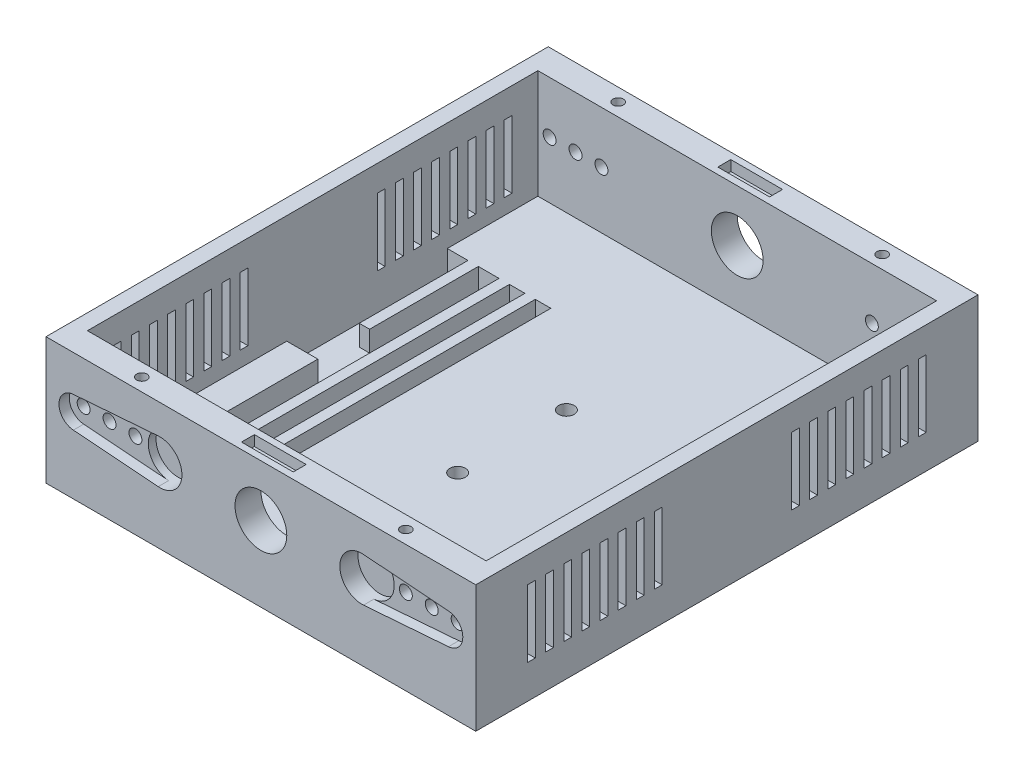
from build123d import *

# Parameters (mm, degrees)
SKETCH1_W           = 83
SKETCH1_H           = 97
BOSS_EXTRUDE1_DEPTH = 6
SKETCH2_W           = 83
SKETCH2_H           = 97
SKETCH2_W_2         = 77
SKETCH2_H_2         = 87
BOSS_EXTRUDE2_DEPTH = 21
SKETCH3_R           = 4.25
CUT_EXTRUDE1_DEPTH  = 3.5
CUT_EXTRUDE2_DEPTH  = 2
SKETCH6_R           = 1.25
CUT_EXTRUDE4_DEPTH  = 5
SKETCH10_R          = 1.5
CUT_EXTRUDE5_DEPTH  = 10
SKETCH11_W          = 3
SKETCH11_H          = 52
CUT_EXTRUDE6_DEPTH  = 4
SKETCH12_W          = 10
SKETCH12_H          = 2.5
CUT_EXTRUDE7_DEPTH  = 2
SKETCH13_R          = 1
CUT_EXTRUDE8_DEPTH  = 5
SKETCH15_W          = 1.5
SKETCH15_H          = 13
CUT_EXTRUDE9_DEPTH  = 101
CHAMFER2_SIZE       = 2.5
SKETCH17_R          = 5
CUT_EXTRUDE10_DEPTH = 105
SKETCH19_W          = 8
SKETCH19_H          = 6
CUT_EXTRUDE11_DEPTH = 10


with BuildPart() as part:
    # Sketch1 → Boss-Extrude1 (new body)
    with BuildSketch(Plane(origin=(0, 0, 0), x_dir=(1, 0, 0), z_dir=(0, 1, 0))):
        with Locations((-3.807692308, 24.440934066)):
            Rectangle(SKETCH1_W, SKETCH1_H)
    extrude(amount=BOSS_EXTRUDE1_DEPTH)

    # Sketch2 → Boss-Extrude2 (add)
    with BuildSketch(Plane(origin=(0, 6, 0), x_dir=(1, 0, 0), z_dir=(0, 1, 0))):
        with Locations((-3.807692308, 24.440934066)):
            Rectangle(SKETCH2_W, SKETCH2_H)
        with Locations((-3.807692308, 24.440934066)):
            Rectangle(SKETCH2_W_2, SKETCH2_H_2, mode=Mode.SUBTRACT)
    extrude(amount=BOSS_EXTRUDE2_DEPTH)

    # Sketch3 → Cut-Extrude1 (cut)
    with BuildSketch(Plane.XY.offset(24.059065934)):
        with Locations((-23.307692308, 17)):
            Circle(SKETCH3_R)
        with Locations((15.692307692, 17)):
            Circle(SKETCH3_R)
    cut_extrude1 = extrude(amount=-CUT_EXTRUDE1_DEPTH, mode=Mode.SUBTRACT)

    # Sketch5 → Cut-Extrude2 (cut)
    with BuildSketch(Plane.XY.offset(24.059065934)):
        with BuildLine():
            Line((-40.034965035, 19.991378797), (-23.629662005, 21.237786629))
            ThreePointArc((-23.629662005, 21.237786629), (-19.057692308, 17), (-23.629662005, 12.762213371))
            Line((-23.629662005, 12.762213371), (-40.034965035, 14.008621203))
            ThreePointArc((-40.034965035, 14.008621203), (-42.807692308, 17), (-40.034965035, 19.991378797))
        make_face()
        with BuildLine():
            Line((16.014277389, 21.237786629), (32.41958042, 19.991378797))
            ThreePointArc((32.41958042, 19.991378797), (35.192307692, 17), (32.41958042, 14.008621203))
            Line((32.41958042, 14.008621203), (16.014277389, 12.762213371))
            ThreePointArc((16.014277389, 12.762213371), (11.442307692, 17), (16.014277389, 21.237786629))
        make_face()
    cut_extrude2 = extrude(amount=-CUT_EXTRUDE2_DEPTH, mode=Mode.SUBTRACT)

    # Sketch6 → Cut-Extrude4 (cut)
    with BuildSketch(Plane.XY.offset(24.059065934)):
        with Locations((-35.037601767, 17)):
            Circle(SKETCH6_R)
        with Locations((-30.037601767, 17)):
            Circle(SKETCH6_R)
        with Locations((22.192307692, 17)):
            Circle(SKETCH6_R)
        with Locations((27.192307692, 17)):
            Circle(SKETCH6_R)
        with Locations((32.192307692, 17)):
            Circle(SKETCH6_R)
        with Locations((-40.037601767, 17)):
            Circle(SKETCH6_R)
    cut_extrude4 = extrude(amount=-CUT_EXTRUDE4_DEPTH, mode=Mode.SUBTRACT)

    # Mirror1: Cut-Extrude1, Cut-Extrude2, Cut-Extrude4 across plane
    add(cut_extrude1.mirror(Plane(origin=(-45.307692308, 27, -24.440934066), x_dir=(1, 0, 0), z_dir=(0, 0, 1))), mode=Mode.SUBTRACT)
    add(cut_extrude2.mirror(Plane(origin=(-45.307692308, 27, -24.440934066), x_dir=(1, 0, 0), z_dir=(0, 0, 1))), mode=Mode.SUBTRACT)
    add(cut_extrude4.mirror(Plane(origin=(-45.307692308, 27, -24.440934066), x_dir=(1, 0, 0), z_dir=(0, 0, 1))), mode=Mode.SUBTRACT)

    # Sketch10 → Cut-Extrude5 (cut)
    with BuildSketch(Plane(origin=(0, 6, 0), x_dir=(1, 0, 0), z_dir=(0, 1, 0))):
        with Locations((-3.807692308, 34.940934066)):
            Circle(SKETCH10_R)
        with Locations((-3.807692308, 13.940934066)):
            Circle(SKETCH10_R)
    extrude(amount=-CUT_EXTRUDE5_DEPTH, mode=Mode.SUBTRACT)

    # Sketch11 → Cut-Extrude6 (cut)
    with BuildSketch(Plane(origin=(0, 6, 0), x_dir=(1, 0, 0), z_dir=(0, 1, 0))):
        Polygon((-36.307692308, 19.440934066), (-36.307692308, -1.559065934), (-32.307692308, -1.559065934), (-32.307692308, 50.440934066), (-36.307692308, 50.440934066), (-36.307692308, 29.440934066), (-38.307692308, 29.440934066), (-38.307692308, 50.440934066), (-42.307692308, 50.440934066), (-42.307692308, 26.940934066), (-42.307692308, 19.440934066), align=None)
        with Locations((-28.807692308, 24.440934066)):
            Rectangle(SKETCH11_W, SKETCH11_H)
        with Locations((-23.807692308, 24.440934066)):
            Rectangle(SKETCH11_W, SKETCH11_H)
    extrude(amount=-CUT_EXTRUDE6_DEPTH, mode=Mode.SUBTRACT)

    # Sketch12 → Cut-Extrude7 (cut)
    with BuildSketch(Plane(origin=(0, 27, 0), x_dir=(1, 0, 0), z_dir=(0, 1, 0))):
        with Locations((-3.807692308, -21.559065934)):
            Rectangle(SKETCH12_W, SKETCH12_H)
        with Locations((-3.807692308, 70.440934066)):
            Rectangle(SKETCH12_W, SKETCH12_H)
    extrude(amount=-CUT_EXTRUDE7_DEPTH, mode=Mode.SUBTRACT)

    # Sketch13 → Cut-Extrude8 (cut)
    with BuildSketch(Plane(origin=(0, 27, 0), x_dir=(1, 0, 0), z_dir=(0, 1, 0))):
        with Locations((-29.307692308, 70.440934066)):
            Circle(SKETCH13_R)
        with Locations((21.692307692, 70.440934066)):
            Circle(SKETCH13_R)
        with Locations((-29.307692308, -21.559065934)):
            Circle(SKETCH13_R)
        with Locations((21.692307692, -21.559065934)):
            Circle(SKETCH13_R)
    extrude(amount=-CUT_EXTRUDE8_DEPTH, mode=Mode.SUBTRACT)

    # Sketch15 → Cut-Extrude9 (cut)
    with BuildSketch(Plane.ZY.offset(45.307692308)):
        with Locations((-62.190934066, 15.5)):
            Rectangle(SKETCH15_W, SKETCH15_H)
        with Locations((-58.690934066, 15.5)):
            Rectangle(SKETCH15_W, SKETCH15_H)
        with Locations((-55.190934066, 15.5)):
            Rectangle(SKETCH15_W, SKETCH15_H)
        with Locations((-51.690934066, 15.5)):
            Rectangle(SKETCH15_W, SKETCH15_H)
        with Locations((-48.190934066, 15.5)):
            Rectangle(SKETCH15_W, SKETCH15_H)
        with Locations((-44.690934066, 15.5)):
            Rectangle(SKETCH15_W, SKETCH15_H)
        with Locations((-41.190934066, 15.5)):
            Rectangle(SKETCH15_W, SKETCH15_H)
        with Locations((-37.690934066, 15.5)):
            Rectangle(SKETCH15_W, SKETCH15_H)
    cut_extrude9 = extrude(amount=-CUT_EXTRUDE9_DEPTH, mode=Mode.SUBTRACT)

    # Mirror2: Cut-Extrude9 across plane
    add(cut_extrude9.mirror(Plane(origin=(-45.307692308, 27, -24.440934066), x_dir=(1, 0, 0), z_dir=(0, 0, 1))), mode=Mode.SUBTRACT)

    # Chamfer2
    chamfer2_edges = [part.edges().sort_by_distance(p)[0] for p in [
        (-3.807692308, 0, -72.940934066),
        (37.692307692, 0, -24.440934066),
        (-3.807692308, 0, 24.059065934),
        (-45.307692308, 0, -24.440934066),
    ]]
    chamfer(chamfer2_edges, length=CHAMFER2_SIZE)

    # Sketch17 → Cut-Extrude10 (cut)
    with BuildSketch(Plane.XY.offset(24.059065934)):
        with Locations((-3.807692308, 17)):
            Circle(SKETCH17_R)
    extrude(amount=-CUT_EXTRUDE10_DEPTH, mode=Mode.SUBTRACT)

    # Sketch19 → Cut-Extrude11 (cut)
    with BuildSketch(Plane(origin=(0, 6, 0), x_dir=(1, 0, 0), z_dir=(0, 1, 0))):
        with Locations((20.692307692, -5.059065934)):
            Rectangle(SKETCH19_W, SKETCH19_H)
        with Locations((20.692307692, 59.940934066)):
            Rectangle(SKETCH19_W, SKETCH19_H)
    extrude(amount=-CUT_EXTRUDE11_DEPTH, mode=Mode.SUBTRACT)


solid = part.part
